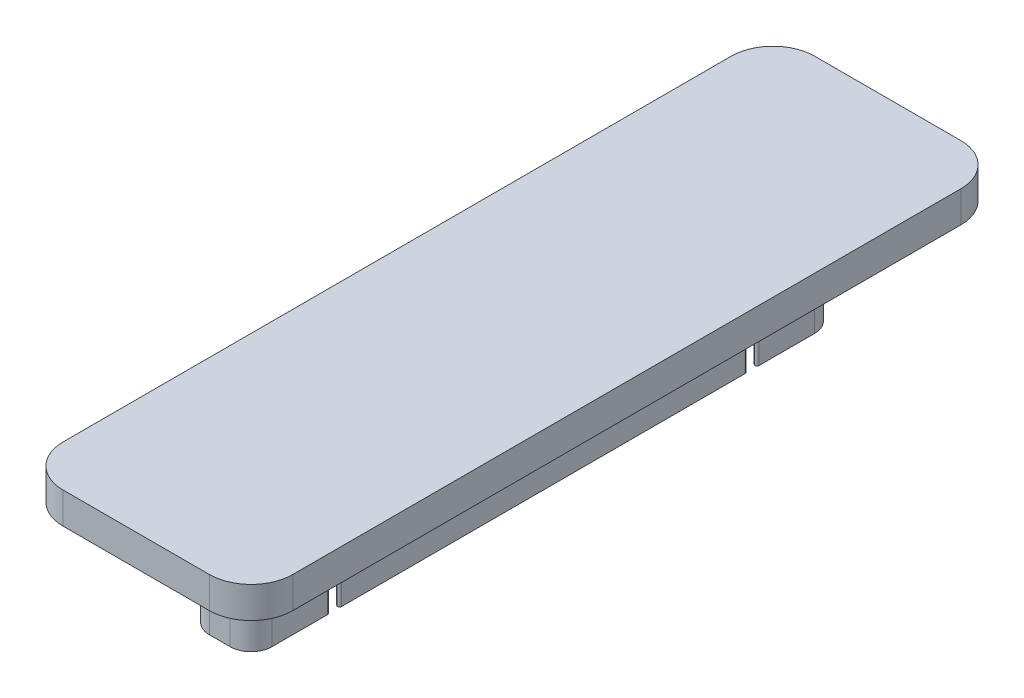
from build123d import *

# Parameters (mm, degrees)
SKETCH_1_W          = 3
SKETCH_1_H          = 28
EXTRUDE_1_DEPTH     = 10
SKETCH_2_W          = 11
SKETCH_2_H          = 24
EXTRUDE_2_DEPTH     = 1.5
FILLET_1_R          = 1
SKETCH_3_W          = 11
SKETCH_3_H          = 36
EXTRUDE_3_DEPTH     = 1.5
FILLET_3_R          = 1
SKETCH_5_W          = 11
SKETCH_5_H          = 30
CUT_EXTRUDE_1_DEPTH = 6.5
CUT_EXTRUDE_2_DEPTH = 3
FILLET_4_R          = 2
FILLET_5_R          = 0.1


with BuildPart() as part:
    # Эскиз1 → Бобышка-Вытянуть1 (new body)
    with BuildSketch(Plane(origin=(0, 0, 0), x_dir=(1, 0, 0), z_dir=(0, 1, 0))):
        Rectangle(SKETCH_1_W, SKETCH_1_H)
    extrude(amount=EXTRUDE_1_DEPTH)

    # Эскиз2 → Бобышка-Вытянуть2 (add)
    with BuildSketch(Plane.XZ):
        Rectangle(SKETCH_2_W, SKETCH_2_H)
    extrude(amount=EXTRUDE_2_DEPTH)

    # Скругление1
    fillet_1_edges = [part.edges().sort_by_distance(p)[0] for p in [
        (-1.5, 5, -14),
        (1.5, 5, -14),
        (1.5, 5, 14),
        (-1.5, 5, 14),
    ]]
    fillet(fillet_1_edges, radius=FILLET_1_R)

    # Эскиз3 → Бобышка-Вытянуть3 (add)
    with BuildSketch(Plane(origin=(0, 10, 0), x_dir=(1, 0, 0), z_dir=(0, 1, 0))):
        Rectangle(SKETCH_3_W, SKETCH_3_H)
    extrude(amount=EXTRUDE_3_DEPTH)

    # Скругление3
    fillet_3_edges = [part.edges().sort_by_distance(p)[0] for p in [
        (5.5, -0.75, -12),
        (5.5, -0.75, 12),
        (-5.5, -0.75, 12),
        (-5.5, -0.75, -12),
    ]]
    fillet(fillet_3_edges, radius=FILLET_3_R)

    # Эскиз5 → Вырез-Вытянуть1 (cut)
    with BuildSketch(Plane(origin=(0, -1.5, 0), x_dir=(-1, 0, 0), z_dir=(0, -1, 0))):
        Rectangle(SKETCH_5_W, SKETCH_5_H)
    extrude(amount=-CUT_EXTRUDE_1_DEPTH, mode=Mode.SUBTRACT)

    # Эскиз6 → Вырез-Вытянуть2 (cut)
    with BuildSketch(Plane.XZ.offset(-5)):
        Polygon((-1.6, -10), (-0.360392927, -8.760392927), (-0.360392927, -8.250794149), (0.360392927, -8.250794149), (0.360392927, -8.760392927), (1.6, -10), (0.360392927, -11.239607073), (0.360392927, -11.788123746), (-0.360392927, -11.788123746), (-0.360392927, -11.239607073), align=None)
        Polygon((-0.360392927, 11.788123746), (0.360392927, 11.788123746), (0.360392927, 11.239607073), (1.6, 10), (0.360392927, 8.760392927), (0.360392927, 8.250794149), (-0.360392927, 8.250794149), (-0.360392927, 8.760392927), (-1.6, 10), (-0.360392927, 11.239607073), align=None)
    extrude(amount=-CUT_EXTRUDE_2_DEPTH, mode=Mode.SUBTRACT)

    # Скругление4
    fillet_4_edges = [part.edges().sort_by_distance(p)[0] for p in [
        (-5.5, 10.75, -18),
        (-5.5, 10.75, 18),
        (5.5, 10.75, 18),
        (5.5, 10.75, -18),
    ]]
    fillet(fillet_4_edges, radius=FILLET_4_R)

    # Скругление5
    fillet_5_edges = [part.edges().sort_by_distance(p)[0] for p in [
        (1.5, 6.5, 10.1),
        (1.5, 6.5, 9.9),
        (-1.5, 6.5, 9.9),
        (-1.5, 6.5, 10.1),
        (1.5, 6.5, -9.9),
        (1.5, 6.5, -10.1),
        (-1.5, 6.5, -10.1),
        (-1.5, 6.5, -9.9),
    ]]
    fillet(fillet_5_edges, radius=FILLET_5_R)


solid = part.part
